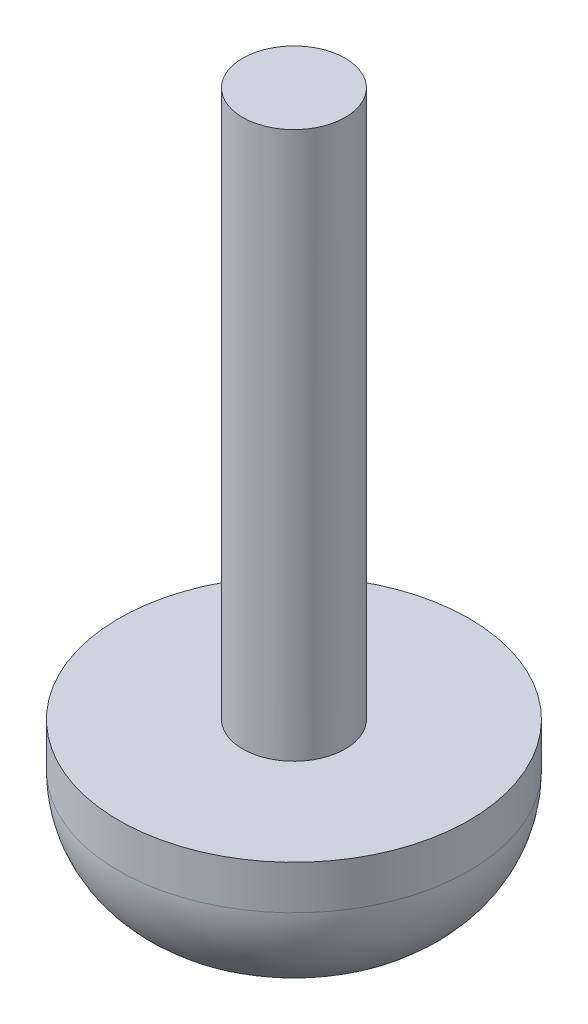
from build123d import *

# Parameters (mm, degrees)
SKETCH1_R           = 0.5953125
BOSS_EXTRUDE1_DEPTH = 3.175
SKETCH2_R           = 2.032
BOSS_EXTRUDE2_DEPTH = 1.778
FILLET1_R           = 1.27
CUT_EXTRUDE1_DEPTH  = 1.27


with BuildPart() as part:
    # Sketch1 → Boss-Extrude1 (new body, symmetric)
    with BuildSketch(Plane(origin=(0, 0, 0), x_dir=(1, 0, 0), z_dir=(0, 1, 0))):
        Circle(SKETCH1_R)
    extrude(amount=BOSS_EXTRUDE1_DEPTH, both=True)

    # Sketch2 → Boss-Extrude2 (add)
    with BuildSketch(Plane.XZ.offset(3.175)):
        Circle(SKETCH2_R)
    extrude(amount=BOSS_EXTRUDE2_DEPTH)

    # Fillet1
    fillet1_edges = [part.edges().sort_by_distance(p)[0] for p in [
        (-2.032, -4.953, 0),
    ]]
    fillet(fillet1_edges, radius=FILLET1_R)

    # Sketch3 → Cut-Extrude1 (cut)
    with BuildSketch(Plane.XZ.offset(4.953)):
        Polygon((-0.508, -0.508), (-1.27, -0.508), (-1.27, 0.508), (-0.508, 0.508), (-0.508, 1.27), (0.508, 1.27), (0.508, 0.508), (1.27, 0.508), (1.27, -0.508), (0.508, -0.508), (0.508, -1.27), (-0.508, -1.27), align=None)
    extrude(amount=-CUT_EXTRUDE1_DEPTH, mode=Mode.SUBTRACT)


solid = part.part
